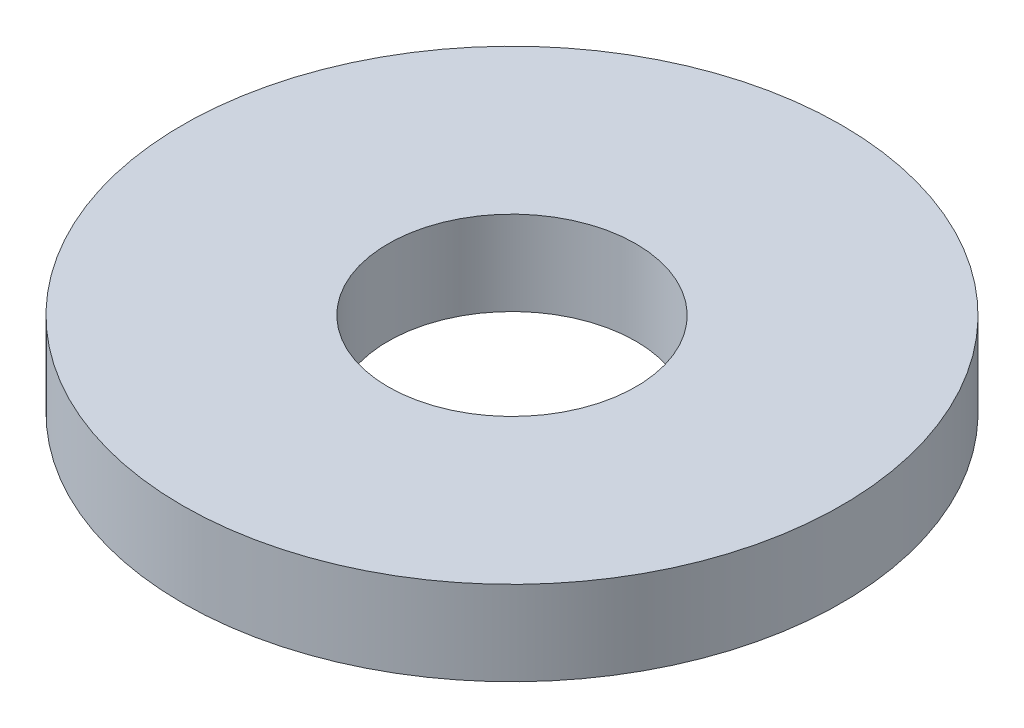
from build123d import *

# Parameters (mm, degrees)
SKETCH1_R           = 3.175
BOSS_EXTRUDE1_DEPTH = 0.8128
SKETCH5_R           = 1.1938
CUT_EXTRUDE1_DEPTH  = 1.8128


with BuildPart() as part:
    # Sketch1 → Boss-Extrude1 (new body)
    with BuildSketch(Plane(origin=(0, 0, 0), x_dir=(1, 0, 0), z_dir=(0, 1, 0))):
        Circle(SKETCH1_R)
    extrude(amount=BOSS_EXTRUDE1_DEPTH)

    # Sketch5 → Cut-Extrude1 (cut, through all)
    with BuildSketch(Plane(origin=(0, 0.8128, 0), x_dir=(-1, 0, 0), z_dir=(0, 1, 0))):
        Circle(SKETCH5_R)
    extrude(amount=-CUT_EXTRUDE1_DEPTH, mode=Mode.SUBTRACT)


solid = part.part
